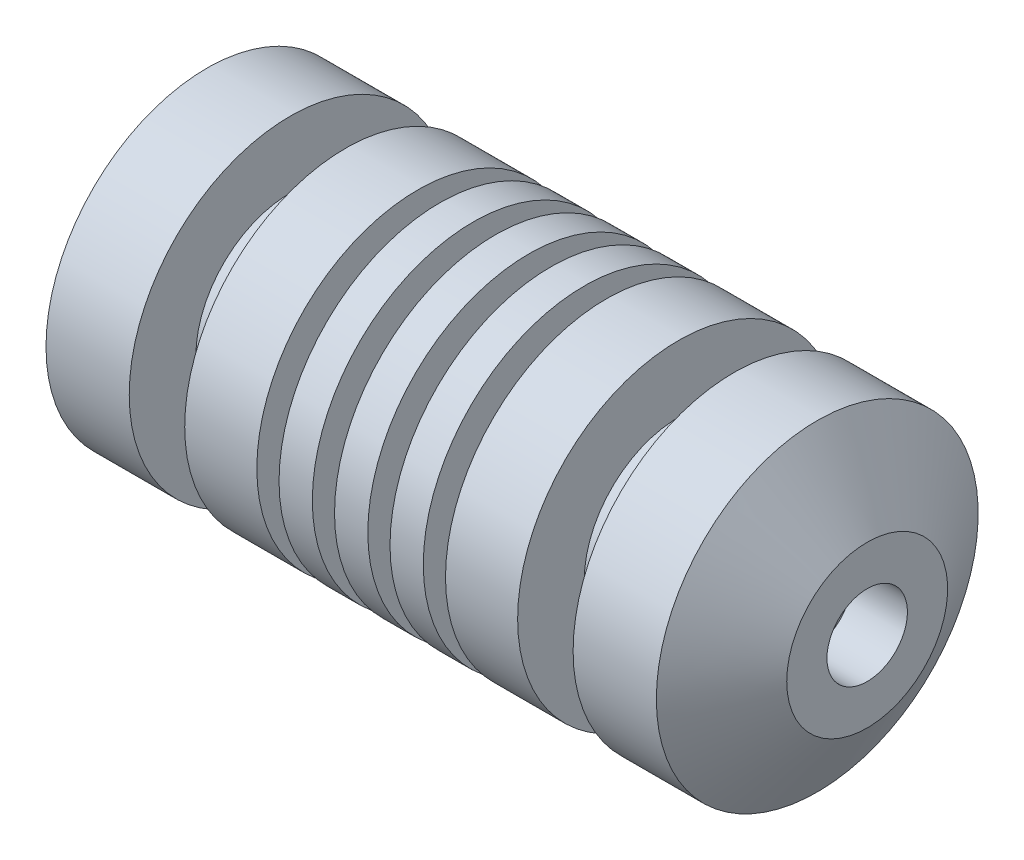
from build123d import *

# Parameters (mm, degrees)
SKETCH3_R          = 3.81
CUT_EXTRUDE1_DEPTH = 2.54
CUT_EXTRUDE1_TAPER = 56


with BuildPart() as part:
    # Sketch1 → Revolve5 (revolve)
    with BuildSketch(Plane.XY):
        Polygon((0, 0), (113.03, 0), (113.03, 3.81), (125.73, 3.81), (125.73, 6.35), (138.43, 6.35), (138.43, 9.2075), (151.13, 9.2075), (151.13, 18.415), (139.700007257, 36.83), (120.650007257, 36.83), (120.650007257, 21.59), (107.950007257, 21.59), (107.950007257, 36.83), (91.440007257, 36.83), (91.440007257, 29.21), (86.360007257, 29.21), (86.360007257, 36.83), (78.740007257, 36.83), (78.740007257, 29.21), (73.660007257, 29.21), (73.660007257, 36.83), (66.040007257, 36.83), (66.040007257, 29.21), (60.960007257, 29.21), (60.960007257, 36.83), (53.340007257, 36.83), (53.340007257, 29.21), (48.260007257, 29.21), (48.260007257, 36.83), (31.750007257, 36.83), (31.750007257, 21.59), (19.050007257, 21.59), (19.050007257, 36.83), (0, 36.83), align=None)
    revolve(axis=Axis((0, 0, 0), (1, 0, 0)))

    # Sketch3 → Cut-Extrude1 (cut)
    with BuildSketch(Plane(origin=(113.03, 0, 0), x_dir=(0, 0, -1), z_dir=(1, 0, 0))):
        Circle(SKETCH3_R)
    extrude(amount=-CUT_EXTRUDE1_DEPTH, taper=CUT_EXTRUDE1_TAPER, mode=Mode.SUBTRACT)


solid = part.part
